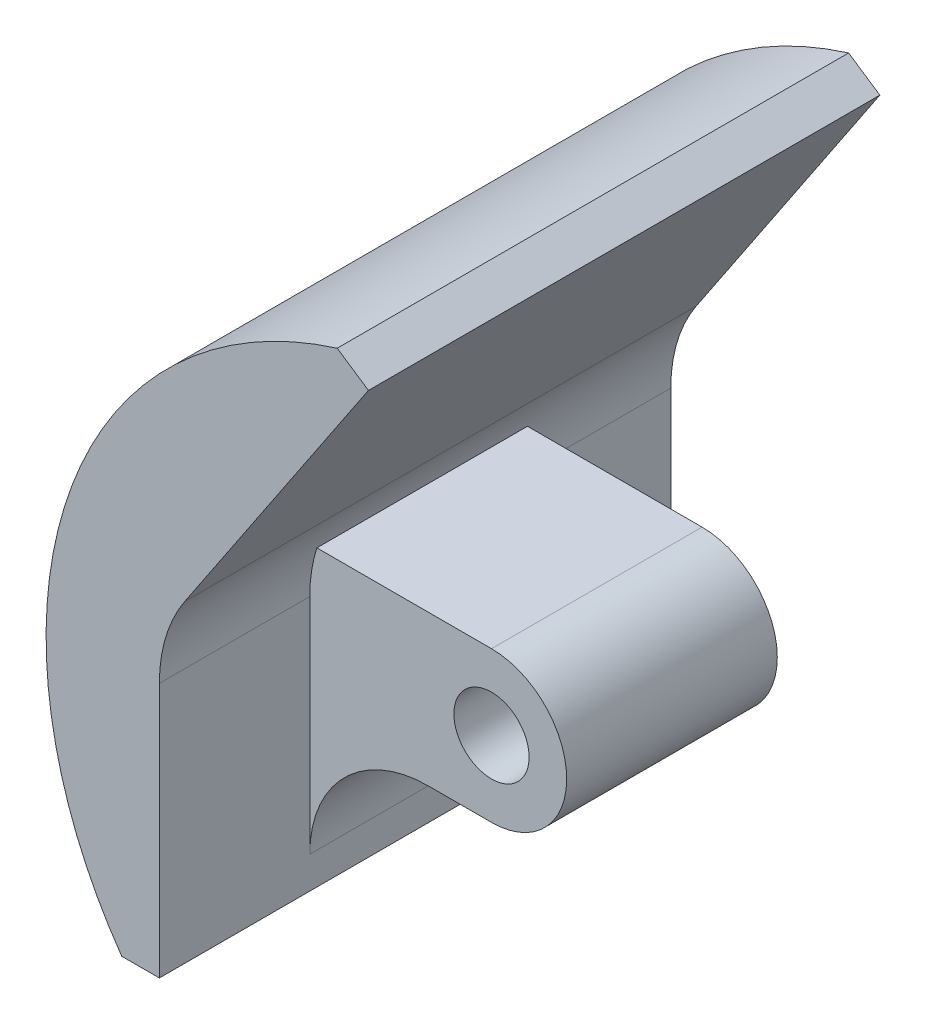
from build123d import *

# Parameters (mm, degrees)
SKETCH1_R                = 6.35
SKETCH1_R_2              = 3.175
BOSS_EXTRUDE1_DEPTH      = 17.78
BOSS_EXTRUDE2_DEPTH      = 17.78
BOSS_EXTRUDE3_DEPTH      = 12.7
BOSS_EXTRUDE3_DEPTH_BACK = 30.48
FILLET1_R                = 10


with BuildPart() as part:
    # Sketch1 → Boss-Extrude1 (new body)
    with BuildSketch(Plane.XY):
        with Locations((-12.7, 137.7)):
            Circle(SKETCH1_R)
        with Locations((-12.7, 137.7)):
            Circle(SKETCH1_R_2, mode=Mode.SUBTRACT)
    extrude(amount=BOSS_EXTRUDE1_DEPTH)

    # Sketch2 → Boss-Extrude2 (add)
    with BuildSketch(Plane.XY.offset(17.78)):
        with BuildLine():
            Line((-12.7, 131.35), (-28.041116719, 131.35))
            Line((-28.041116719, 131.35), (-28.041116719, 144.05))
            Line((-28.041116719, 144.05), (-12.7, 144.05))
            ThreePointArc((-12.7, 144.05), (-19.05, 137.7), (-12.7, 131.35))
        make_face()
    extrude(amount=-BOSS_EXTRUDE2_DEPTH)

    # Sketch3 → Boss-Extrude3 (add, two sides)
    with BuildSketch(Plane.XY.offset(17.78)) as boss_extrude3_sk:
        with BuildLine():
            Line((-28.041116719, 131.35), (-28.041116719, 118.65))
            Line((-28.041116719, 118.65), (-31.216116719, 118.65))
            ThreePointArc((-31.216116719, 118.65), (-35.746712734, 150.055233925), (-13.026751575, 172.205140992))
            Line((-13.026751575, 172.205140992), (-10.387770933, 170.439806414))
            Line((-10.387770933, 170.439806414), (-25.897039285, 147.25515947))
            ThreePointArc((-25.897039285, 147.25515947), (-27.493281477, 143.883657427), (-28.041116719, 140.193821156))
            Line((-28.041116719, 140.193821156), (-28.041116719, 131.35))
        make_face()
    extrude(amount=BOSS_EXTRUDE3_DEPTH)
    extrude(boss_extrude3_sk.sketch, amount=-BOSS_EXTRUDE3_DEPTH_BACK)

    # Fillet1
    fillet1_edges = [part.edges().sort_by_distance(p)[0] for p in [
        (-28.041116719, 131.35, 8.89),
    ]]
    fillet(fillet1_edges, radius=FILLET1_R)


solid = part.part
